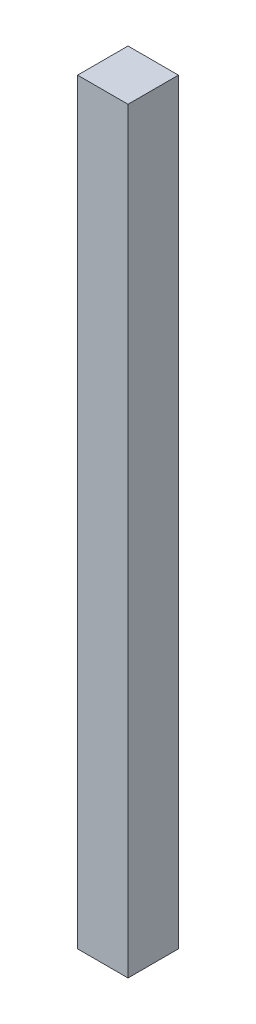
from build123d import *

# Parameters (mm, degrees)
SKETCH_1_W      = 200
SKETCH_1_H      = 200
EXTRUDE_2_DEPTH = 3000


with BuildPart() as part:
    # 草图1 → 凸台-拉伸2 (new body)
    with BuildSketch(Plane(origin=(0, 0, 0), x_dir=(1, 0, 0), z_dir=(0, 1, 0))):
        Rectangle(SKETCH_1_W, SKETCH_1_H)
    extrude(amount=-EXTRUDE_2_DEPTH)


solid = part.part
